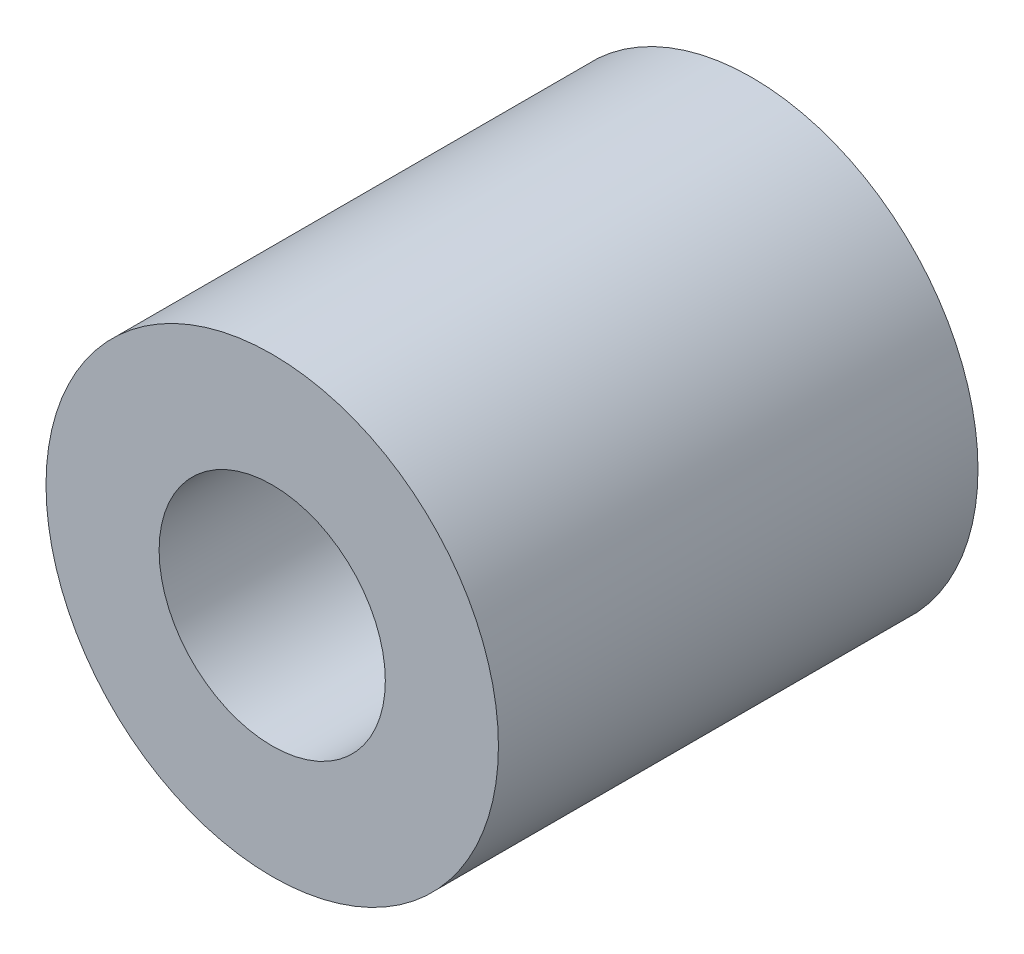
from build123d import *

# Parameters (mm, degrees)
SKETCH1_R                 = 5
BOSS_EXTRUDE1_DEPTH       = 10.6
F_5_0MM_DOWEL_HOLE1_D     = 5
F_5_0MM_DOWEL_HOLE1_DEPTH = 10.6


with BuildPart() as part:
    # Sketch1 → Boss-Extrude1 (new body)
    with BuildSketch(Plane.XY):
        Circle(SKETCH1_R)
    extrude(amount=BOSS_EXTRUDE1_DEPTH)

    # Ø5.0mm Dowel Hole1
    with Locations(Plane.XY.offset(10.6)):
        with Locations((0, 0)):
            Hole(F_5_0MM_DOWEL_HOLE1_D / 2, depth=F_5_0MM_DOWEL_HOLE1_DEPTH)


solid = part.part
